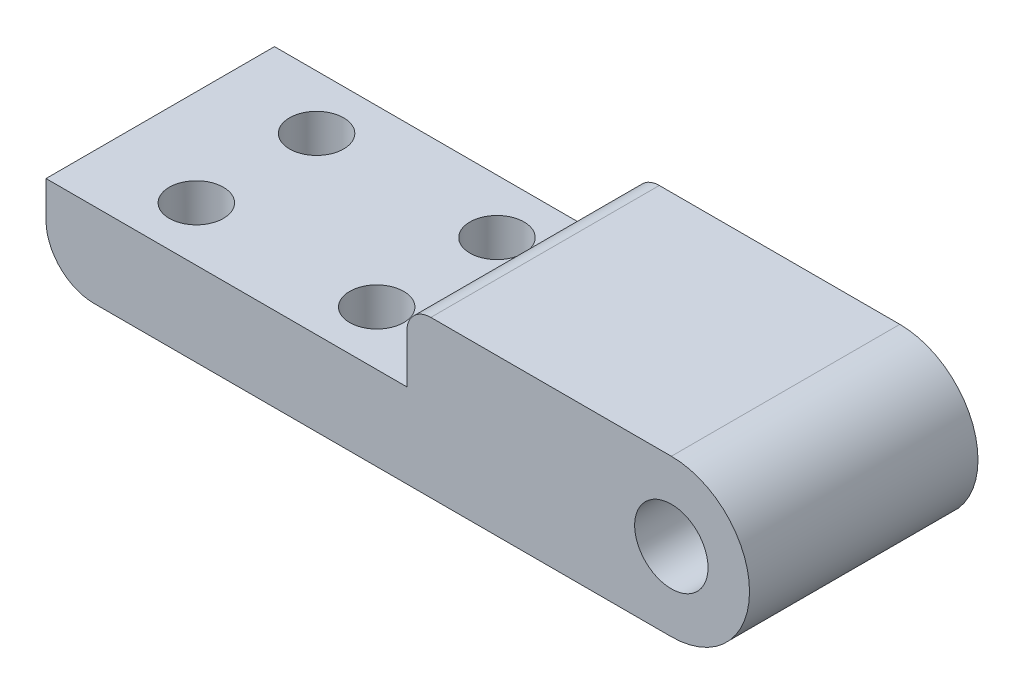
from build123d import *

# Parameters (mm, degrees)
SKETCH_1_R          = 3.05
EXTRUDE_1_DEPTH     = 19
SKETCH_2_R          = 2.25
CUT_EXTRUDE_1_DEPTH = 20
FILLET_1_R          = 4
FILLET_2_R          = 2


with BuildPart() as part:
    # 草图1 → 凸台-拉伸1 (new body)
    with BuildSketch(Plane.XY):
        with BuildLine():
            Line((1.728973827, 8.951048951), (23.728973827, 8.951048951))
            ThreePointArc((23.728973827, 8.951048951), (30.228973827, 2.451048951), (23.728973827, -4.048951049))
            Line((23.728973827, -4.048951049), (-28.271026173, -4.048951049))
            Line((-28.271026173, -4.048951049), (-28.271026173, 2.951048951))
            Line((-28.271026173, 2.951048951), (1.728973827, 2.951048951))
            Line((1.728973827, 2.951048951), (1.728973827, 8.951048951))
        make_face()
        with Locations((23.728973827, 2.451048951)):
            Circle(SKETCH_1_R, mode=Mode.SUBTRACT)
    extrude(amount=EXTRUDE_1_DEPTH)

    # 草图2 → 切除-拉伸1 (cut)
    with BuildSketch(Plane(origin=(0, 2.951048951, 0), x_dir=(1, 0, 0), z_dir=(0, 1, 0))):
        with Locations((-20.271026173, -4.5)):
            Circle(SKETCH_2_R)
        with Locations((-5.271026173, -4.5)):
            Circle(SKETCH_2_R)
        with Locations((-5.271026173, -14.5)):
            Circle(SKETCH_2_R)
        with Locations((-20.271026173, -14.5)):
            Circle(SKETCH_2_R)
    extrude(amount=-CUT_EXTRUDE_1_DEPTH, mode=Mode.SUBTRACT)

    # 圆角1
    fillet_1_edges = [part.edges().sort_by_distance(p)[0] for p in [
        (-28.271026173, -4.048951049, 9.5),
    ]]
    fillet(fillet_1_edges, radius=FILLET_1_R)

    # 圆角2
    fillet_2_edges = [part.edges().sort_by_distance(p)[0] for p in [
        (1.728973827, 8.951048951, 9.5),
    ]]
    fillet(fillet_2_edges, radius=FILLET_2_R)


solid = part.part
